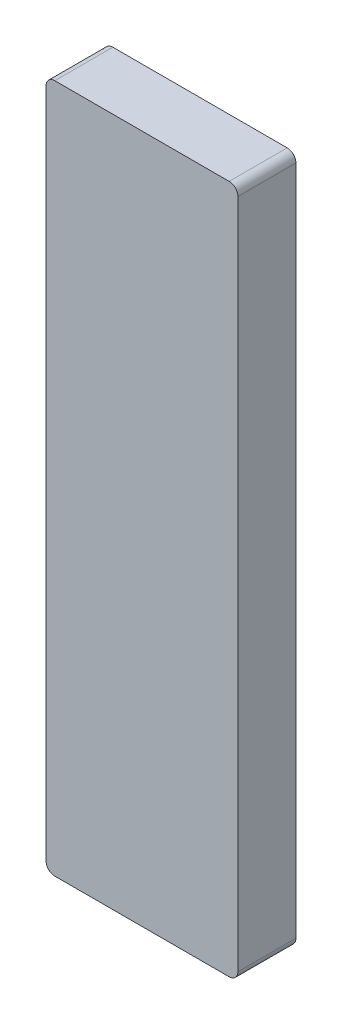
from build123d import *

# Parameters (mm, degrees)
BOSS_EXTRUDE1_DEPTH = 169.05


with BuildPart() as part:
    # Sketch1 → Boss-Extrude1 (new body)
    with BuildSketch(Plane.XY):
        with BuildLine():
            Line((25.4, 0), (533.4, 0))
            ThreePointArc((533.4, 0), (551.360512242, -7.439487758), (558.8, -25.4))
            Line((558.8, -25.4), (558.8, -1981.2))
            ThreePointArc((558.8, -1981.2), (551.360512242, -1999.160512242), (533.4, -2006.6))
            Line((533.4, -2006.6), (25.4, -2006.6))
            ThreePointArc((25.4, -2006.6), (7.439487758, -1999.160512242), (0, -1981.2))
            Line((0, -1981.2), (0, -25.4))
            ThreePointArc((0, -25.4), (7.439487758, -7.439487758), (25.4, 0))
        make_face()
    extrude(amount=BOSS_EXTRUDE1_DEPTH)


solid = part.part
